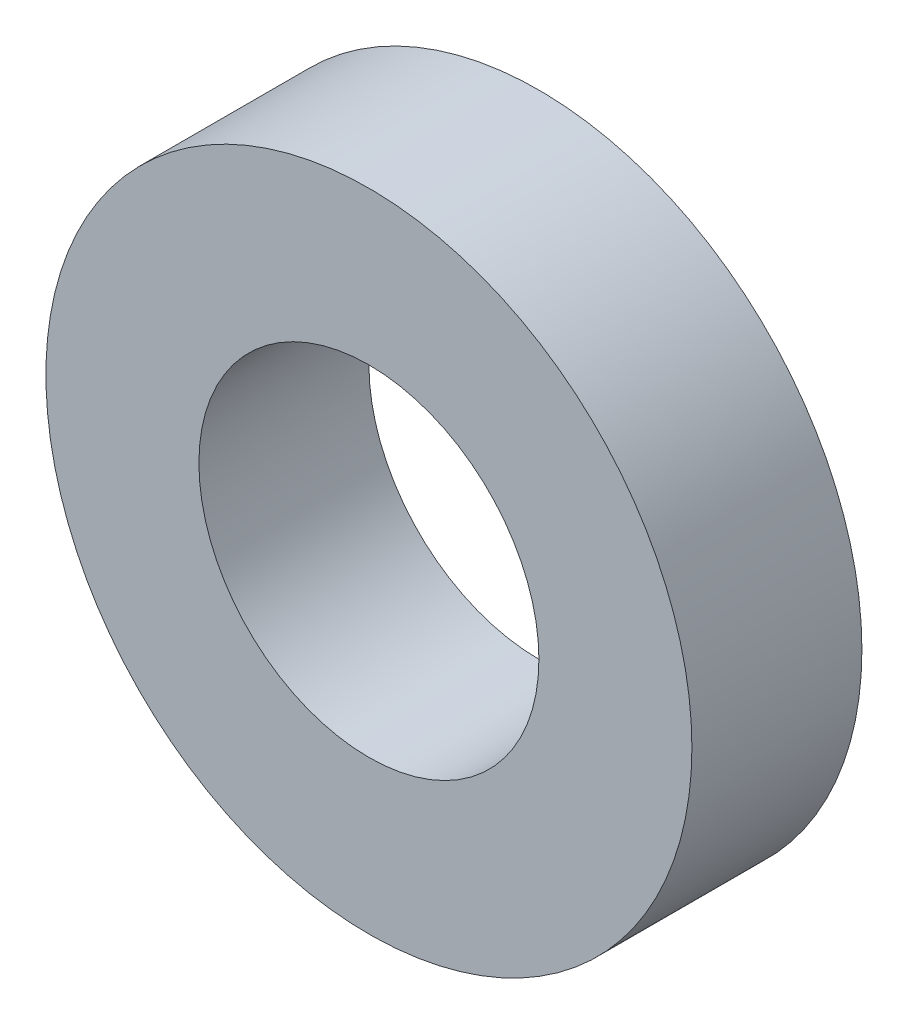
from build123d import *

# Parameters (mm, degrees)
CROQUIS1_R              = 9.5
SALIENTE_EXTRUIR1_DEPTH = 5
CROQUIS2_R              = 5
CORTAR_EXTRUIR1_DEPTH   = 6.35


with BuildPart() as part:
    # Croquis1 → Saliente-Extruir1 (new body)
    with BuildSketch(Plane.XY):
        Circle(CROQUIS1_R)
    extrude(amount=SALIENTE_EXTRUIR1_DEPTH)

    # Croquis2 → Cortar-Extruir1 (cut)
    with BuildSketch(Plane.XY.offset(5)):
        Circle(CROQUIS2_R)
    extrude(amount=-CORTAR_EXTRUIR1_DEPTH, mode=Mode.SUBTRACT)


solid = part.part
